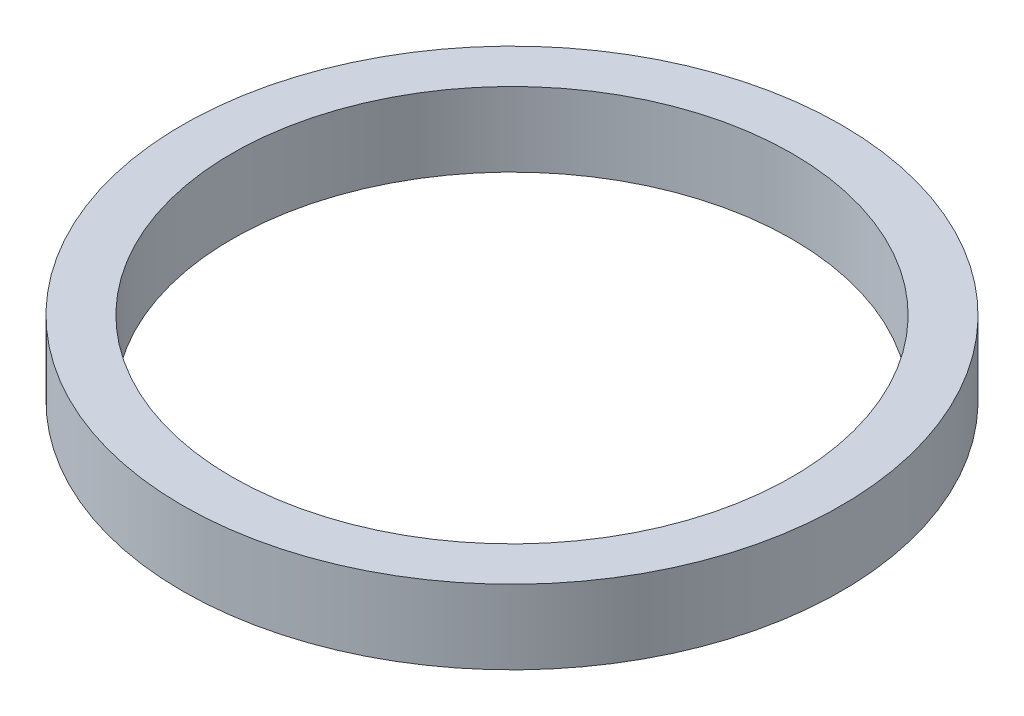
from build123d import *

# Parameters (mm, degrees)
SKETCH1_R           = 25.4
SKETCH1_R_2         = 21.59
BOSS_EXTRUDE1_DEPTH = 5.715


with BuildPart() as part:
    # Sketch1 → Boss-Extrude1 (new body)
    with BuildSketch(Plane(origin=(0, 0, 0), x_dir=(1, 0, 0), z_dir=(0, 1, 0))):
        Circle(SKETCH1_R)
        Circle(SKETCH1_R_2, mode=Mode.SUBTRACT)
    extrude(amount=BOSS_EXTRUDE1_DEPTH)


solid = part.part
